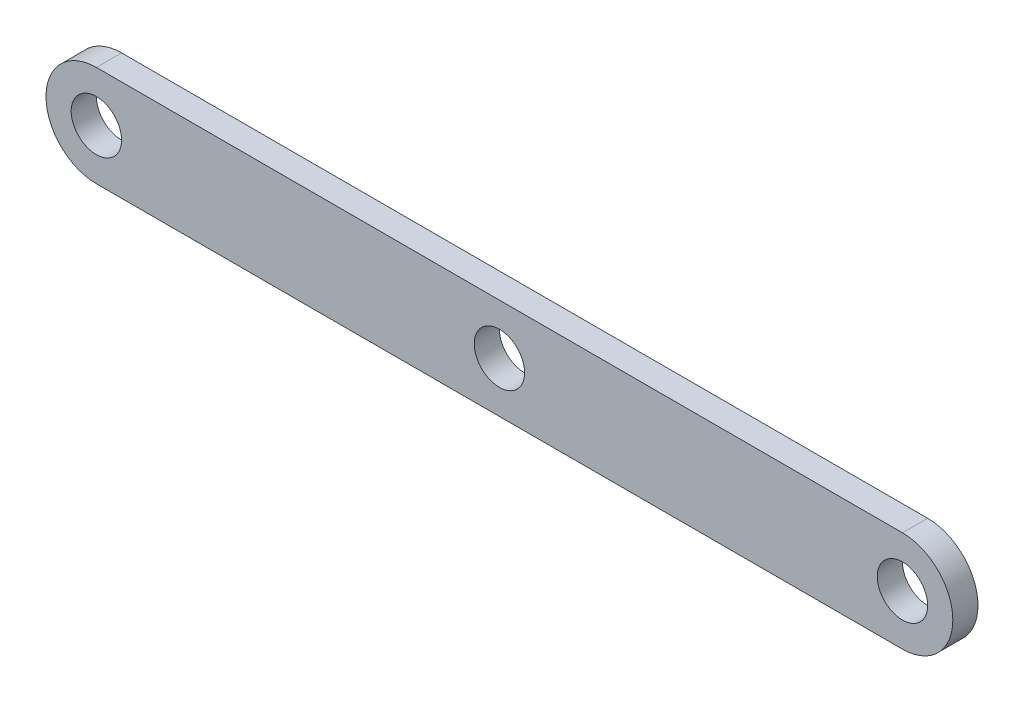
from build123d import *

# Parameters (mm, degrees)
SKETCH1_R           = 3.175
BOSS_EXTRUDE1_DEPTH = 3.175


with BuildPart() as part:
    # Sketch1 → Boss-Extrude1 (new body)
    with BuildSketch(Plane.XY):
        with BuildLine():
            Line((0, 6.35), (101.6, 6.35))
            ThreePointArc((101.6, 6.35), (107.95, 0), (101.6, -6.35))
            Line((101.6, -6.35), (0, -6.35))
            ThreePointArc((0, -6.35), (-6.35, 0), (0, 6.35))
        make_face()
        Circle(SKETCH1_R, mode=Mode.SUBTRACT)
        with Locations((101.6, 0)):
            Circle(SKETCH1_R, mode=Mode.SUBTRACT)
        with Locations((50.8, 0)):
            Circle(SKETCH1_R, mode=Mode.SUBTRACT)
    extrude(amount=BOSS_EXTRUDE1_DEPTH)


solid = part.part
